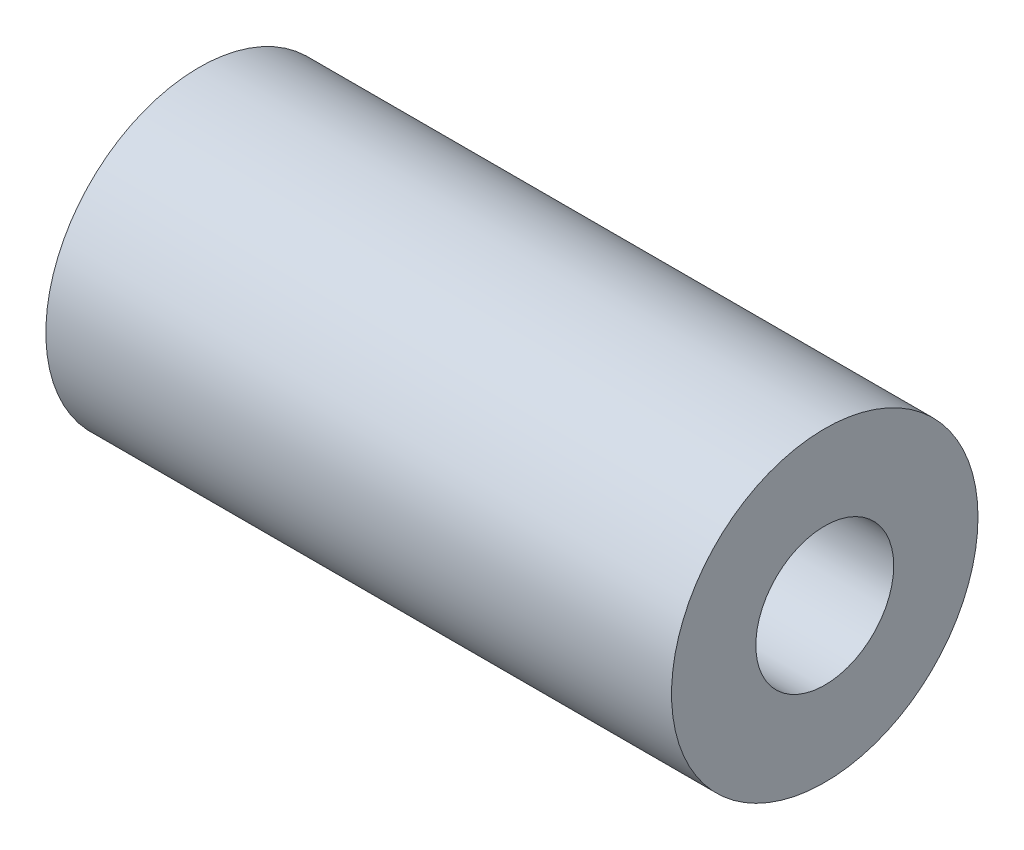
from build123d import *

# Parameters (mm, degrees)
SKETCH_1_R      = 6
SKETCH_1_R_2    = 2.7
EXTRUDE_1_DEPTH = 24.5


with BuildPart() as part:
    # 草图1 → 凸台-拉伸1 (new body)
    with BuildSketch(Plane(origin=(0, 0, 0), x_dir=(0, 0, -1), z_dir=(1, 0, 0))):
        Circle(SKETCH_1_R)
        Circle(SKETCH_1_R_2, mode=Mode.SUBTRACT)
    extrude(amount=EXTRUDE_1_DEPTH)


solid = part.part
